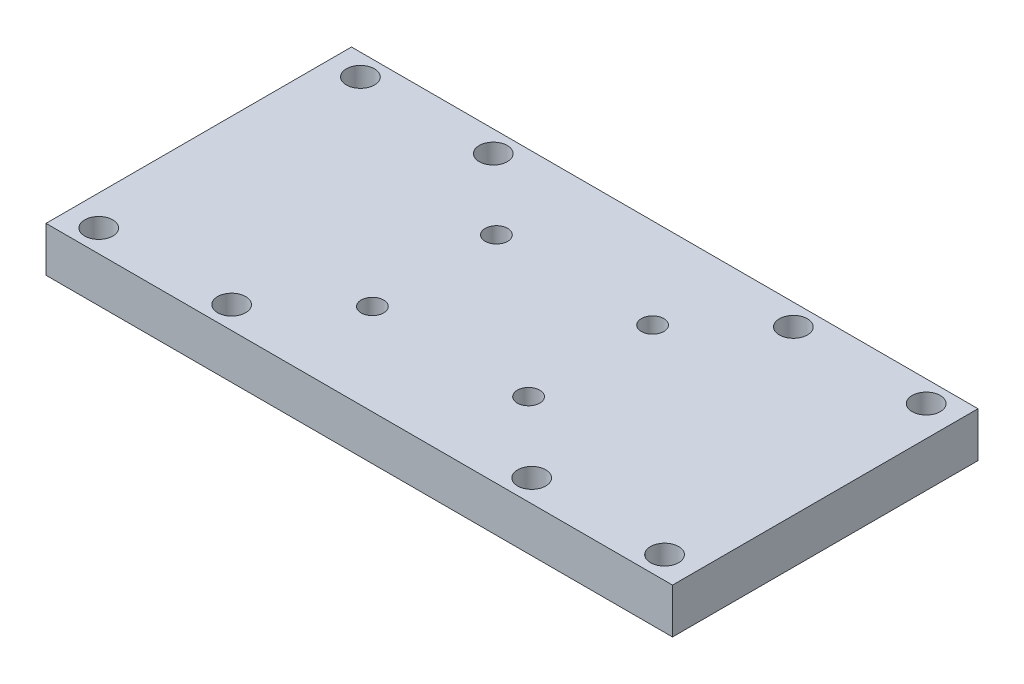
from build123d import *

# Parameters (mm, degrees)
SKETCH1_W           = 111.425838438
SKETCH1_H           = 54.328747314
SKETCH1_R           = 2.5
SKETCH1_R_2         = 2
BOSS_EXTRUDE1_DEPTH = 8


with BuildPart() as part:
    # Sketch1 → Boss-Extrude1 (new body)
    with BuildSketch(Plane(origin=(0, 0, 0), x_dir=(1, 0, 0), z_dir=(0, 1, 0))):
        with Locations((-29.683937911, 8.450172106)):
            Rectangle(SKETCH1_W, SKETCH1_H)
        with Locations((20.630003191, 31.802423001)):
            Circle(SKETCH1_R, mode=Mode.SUBTRACT)
        with Locations((-2.997879012, 31.802423001)):
            Circle(SKETCH1_R, mode=Mode.SUBTRACT)
        with Locations((20.630003191, -14.729057301)):
            Circle(SKETCH1_R, mode=Mode.SUBTRACT)
        with Locations((-2.997879012, -14.729057301)):
            Circle(SKETCH1_R, mode=Mode.SUBTRACT)
        with Locations((-43.574368795, 19.565565741)):
            Circle(SKETCH1_R_2, mode=Mode.SUBTRACT)
        with Locations((-15.793507027, 19.565565741)):
            Circle(SKETCH1_R_2, mode=Mode.SUBTRACT)
        with Locations((-15.793507027, -2.492200041)):
            Circle(SKETCH1_R_2, mode=Mode.SUBTRACT)
        with Locations((-43.574368795, -2.492200041)):
            Circle(SKETCH1_R_2, mode=Mode.SUBTRACT)
        with Locations((-56.369996809, 31.802423001)):
            Circle(SKETCH1_R, mode=Mode.SUBTRACT)
        with Locations((-79.997879012, 31.802423001)):
            Circle(SKETCH1_R, mode=Mode.SUBTRACT)
        with Locations((-79.997879012, -14.729057301)):
            Circle(SKETCH1_R, mode=Mode.SUBTRACT)
        with Locations((-56.369996809, -14.729057301)):
            Circle(SKETCH1_R, mode=Mode.SUBTRACT)
    extrude(amount=BOSS_EXTRUDE1_DEPTH)


solid = part.part
